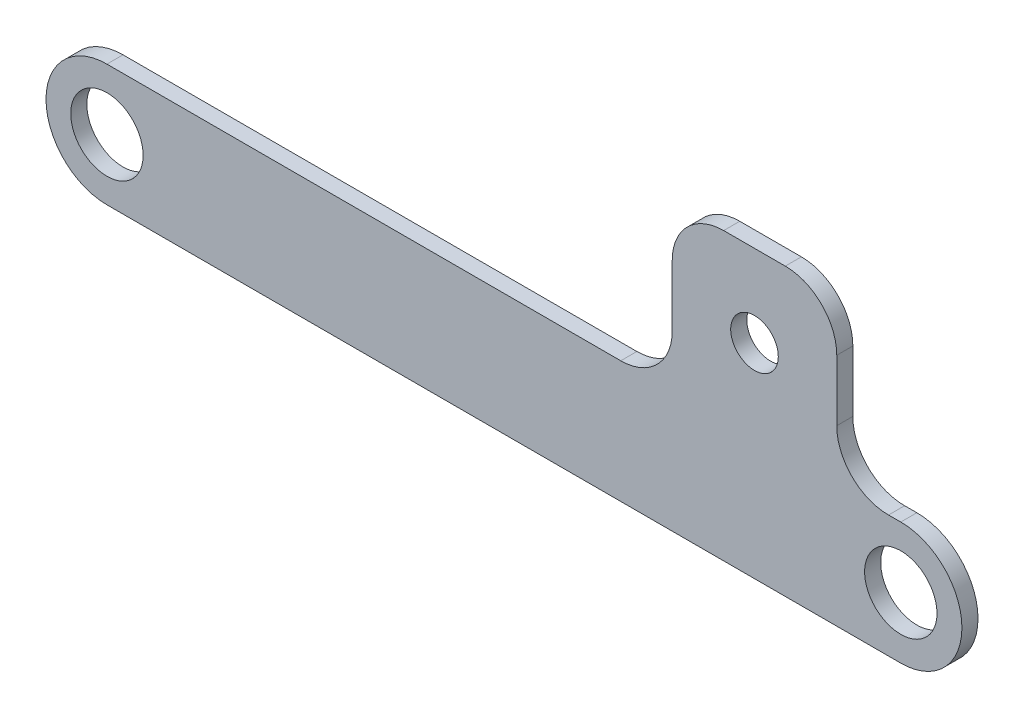
from build123d import *

# Parameters (mm, degrees)
SKETCH1_R           = 14.2875
SKETCH1_R_2         = 9.398
BOSS_EXTRUDE1_DEPTH = 6.35
FILLET1_R           = 20.32
FILLET4_R           = 20.32
FILLET5_R           = 20.32
FILLET6_R           = 20.32


with BuildPart() as part:
    # Sketch1 → Boss-Extrude1 (new body)
    with BuildSketch(Plane.XY):
        with BuildLine():
            Line((0, -24.13), (-313.436, -24.13))
            ThreePointArc((-313.436, -24.13), (-337.49260416, -0.07339584), (-313.436, 23.98320832))
            Line((-313.436, 23.98320832), (-90.24339584, 23.98320832))
            Line((-90.24339584, 23.98320832), (-90.24339584, 88.82660416))
            Line((-90.24339584, 88.82660416), (-25.286322176, 88.82660416))
            Line((-25.286322176, 88.82660416), (-25.286322176, 23.98320832))
            Line((-25.286322176, 23.98320832), (0, 24.13))
            ThreePointArc((0, 24.13), (24.13, 0), (0, -24.13))
        make_face()
        with Locations((-313.436, -0.07339584)):
            Circle(SKETCH1_R, mode=Mode.SUBTRACT)
        Circle(SKETCH1_R, mode=Mode.SUBTRACT)
        with Locations((-57.764858946, 56.47830208)):
            Circle(SKETCH1_R_2, mode=Mode.SUBTRACT)
    extrude(amount=BOSS_EXTRUDE1_DEPTH)

    # Fillet1
    fillet1_edges = [part.edges().sort_by_distance(p)[0] for p in [
        (-90.24339584, 23.98320832, 3.175),
    ]]
    fillet(fillet1_edges, radius=FILLET1_R)

    # Fillet4
    fillet4_edges = [part.edges().sort_by_distance(p)[0] for p in [
        (-25.286322176, 23.98320832, 3.175),
    ]]
    fillet(fillet4_edges, radius=FILLET4_R)

    # Fillet5
    fillet5_edges = [part.edges().sort_by_distance(p)[0] for p in [
        (-25.286322176, 88.82660416, 3.175),
    ]]
    fillet(fillet5_edges, radius=FILLET5_R)

    # Fillet6
    fillet6_edges = [part.edges().sort_by_distance(p)[0] for p in [
        (-90.24339584, 88.82660416, 3.175),
    ]]
    fillet(fillet6_edges, radius=FILLET6_R)


solid = part.part
